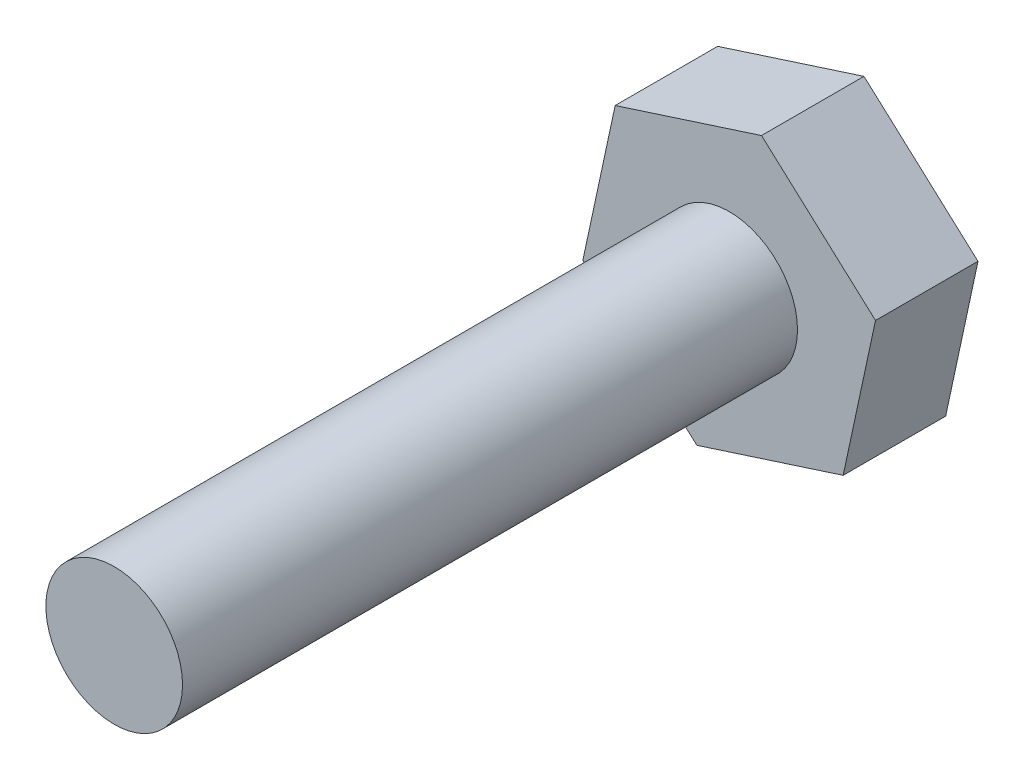
from build123d import *

# Parameters (mm, degrees)
BOSS_EXTRUDE1_DEPTH = 3
SKETCH2_R           = 2
BOSS_EXTRUDE2_DEPTH = 18


with BuildPart() as part:
    # Sketch1 → Boss-Extrude1 (new body)
    with BuildSketch(Plane.XY):
        Polygon((3.33681456, -3.019216553), (4.283125514, 1.3801579), (0.946310955, 4.399374453), (-3.33681456, 3.019216553), (-4.283125514, -1.3801579), (-0.946310955, -4.399374453), align=None)
    extrude(amount=BOSS_EXTRUDE1_DEPTH)

    # Sketch2 → Boss-Extrude2 (add)
    with BuildSketch(Plane.XY.offset(3)):
        Circle(SKETCH2_R)
    extrude(amount=BOSS_EXTRUDE2_DEPTH)


solid = part.part
